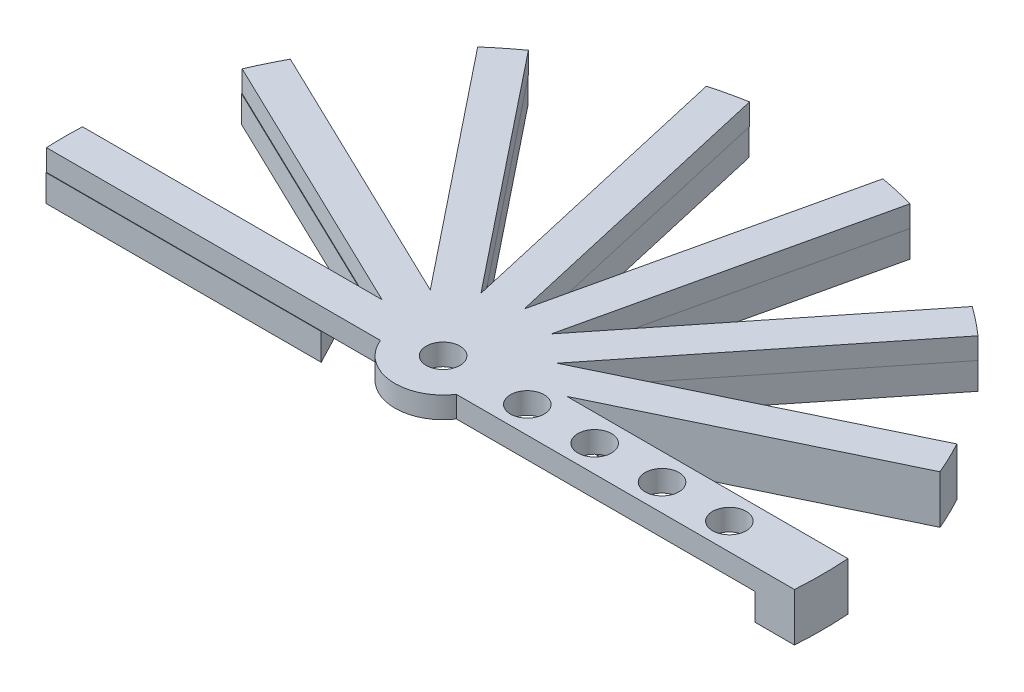
from build123d import *

# Parameters (mm, degrees)
SKETCH1_R           = 2
BOSS_EXTRUDE1_DEPTH = 2.54
BOSS_EXTRUDE2_DEPTH = 3.175
SKETCH4_W           = 8.755126744
SKETCH4_H           = 6.35
BOSS_EXTRUDE3_DEPTH = 3.175
SKETCH5_R           = 56.952437084
SKETCH5_R_2         = 45.011733307
CUT_EXTRUDE1_DEPTH  = 15.24


with BuildPart() as part:
    # Sketch1 → Boss-Extrude1 (new body)
    with BuildSketch(Plane(origin=(0, 0, 0), x_dir=(1, 0, 0), z_dir=(0, 1, 0))):
        with BuildLine():
            Line((-12.877451354, 48.231560826), (-17.055698858, 47.277903099))
            Line((-17.055698858, 47.277903099), (-8.251532809, 8.704331291))
            Line((-8.251532809, 8.704331291), (-32.920257894, 39.637934129))
            Line((-32.920257894, 39.637934129), (-36.270952237, 36.965844556))
            Line((-36.270952237, 36.965844556), (-11.602227151, 6.032241718))
            Line((-11.602227151, 6.032241718), (-47.249567728, 23.199096168))
            Line((-47.249567728, 23.199096168), (-49.109062801, 19.337814861))
            Line((-49.109062801, 19.337814861), (-13.461722225, 2.170960411))
            Line((-13.461722225, 2.170960411), (-53.027285305, 2.170960411))
            Line((-53.027285305, 2.170960411), (-53.027285305, -2.114738512))
            Line((-53.027285305, -2.114738512), (-9.372018351, -2.114738512))
            ThreePointArc((-9.372018351, -2.114738512), (-4.657137499, -5.657616121), (0.679371921, -3.14688905))
            Line((0.679371921, -3.14688905), (44.880714695, -3.14688905))
            Line((44.880714695, -3.14688905), (44.880714695, 0.02811095))
            Line((44.880714695, 0.02811095), (44.880714695, 3.20311095))
            Line((44.880714695, 3.20311095), (7.458434292, 3.20311095))
            Line((7.458434292, 3.20311095), (40.962492191, 19.337814861))
            Line((40.962492191, 19.337814861), (39.102997117, 23.199096168))
            Line((39.102997117, 23.199096168), (3.455656541, 6.032241718))
            Line((3.455656541, 6.032241718), (28.124381626, 36.965844556))
            Line((28.124381626, 36.965844556), (24.773687284, 39.637934129))
            Line((24.773687284, 39.637934129), (0.104962198, 8.704331291))
            Line((0.104962198, 8.704331291), (8.909128247, 47.277903099))
            Line((8.909128247, 47.277903099), (4.730880744, 48.231560826))
            Line((4.730880744, 48.231560826), (-4.073285305, 9.657989018))
            Line((-4.073285305, 9.657989018), (-12.877451354, 48.231560826))
        make_face()
        with Locations((-4.073285305, 0.02811095)):
            Circle(SKETCH1_R, mode=Mode.SUBTRACT)
        with Locations((5.926714695, 0.02811095)):
            Circle(SKETCH1_R, mode=Mode.SUBTRACT)
        with Locations((13.926714695, 0.02811095)):
            Circle(SKETCH1_R, mode=Mode.SUBTRACT)
        with Locations((21.926714695, 0.02811095)):
            Circle(SKETCH1_R, mode=Mode.SUBTRACT)
        with Locations((29.926714695, 0.02811095)):
            Circle(SKETCH1_R, mode=Mode.SUBTRACT)
    extrude(amount=BOSS_EXTRUDE1_DEPTH)

    # Sketch3 → Boss-Extrude2 (add)
    with BuildSketch(Plane.XZ):
        Polygon((40.962492191, -19.337814861), (39.102997117, -23.199096168), (6.04600763, -7.279689057), (9.932157206, -4.394393119), align=None)
        Polygon((6.638401546, -10.036078698), (28.111723935, -36.963461939), (24.76099628, -39.635509739), (1.885207385, -10.949444147), align=None)
        Polygon((1.222949052, -13.689887234), (8.885971689, -47.267642171), (4.707700409, -48.221195721), (-3.455809874, -12.450409084), align=None)
        Polygon((-5.241544906, -14.632097606), (-12.906660536, -48.209374817), (-17.08487237, -47.255560825), (-8.919132396, -11.485283116), align=None)
        Polygon((-11.474638084, -12.676083302), (-32.949638901, -39.602127989), (-36.300199991, -36.929871333), (-13.422623046, -8.245231717), align=None)
        Polygon((-16.241722503, -8.209278105), (-47.272988898, -23.150765598), (-49.132243282, -19.28936839), (-16.074261552, -3.372021857), align=None)
        Polygon((-18.598567057, -2.116435888), (-53.039640443, -2.113859702), (-53.039319873, 2.171839209), (-16.348829699, 2.169094767), align=None)
    extrude(amount=BOSS_EXTRUDE2_DEPTH)

    # Sketch4 → Boss-Extrude3 (add)
    with BuildSketch(Plane.XZ):
        with Locations((40.503151323, -0.02811095)):
            Rectangle(SKETCH4_W, SKETCH4_H)
    extrude(amount=BOSS_EXTRUDE3_DEPTH)

    # Sketch5 → Cut-Extrude1 (cut)
    with BuildSketch(Plane(origin=(0, 2.54, 0), x_dir=(1, 0, 0), z_dir=(0, 1, 0))):
        with Locations((-4.073285305, 0.02811095)):
            Circle(SKETCH5_R)
        with Locations((-4.073285305, 0.02811095)):
            Circle(SKETCH5_R_2, mode=Mode.SUBTRACT)
    extrude(amount=-CUT_EXTRUDE1_DEPTH, mode=Mode.SUBTRACT)


solid = part.part
